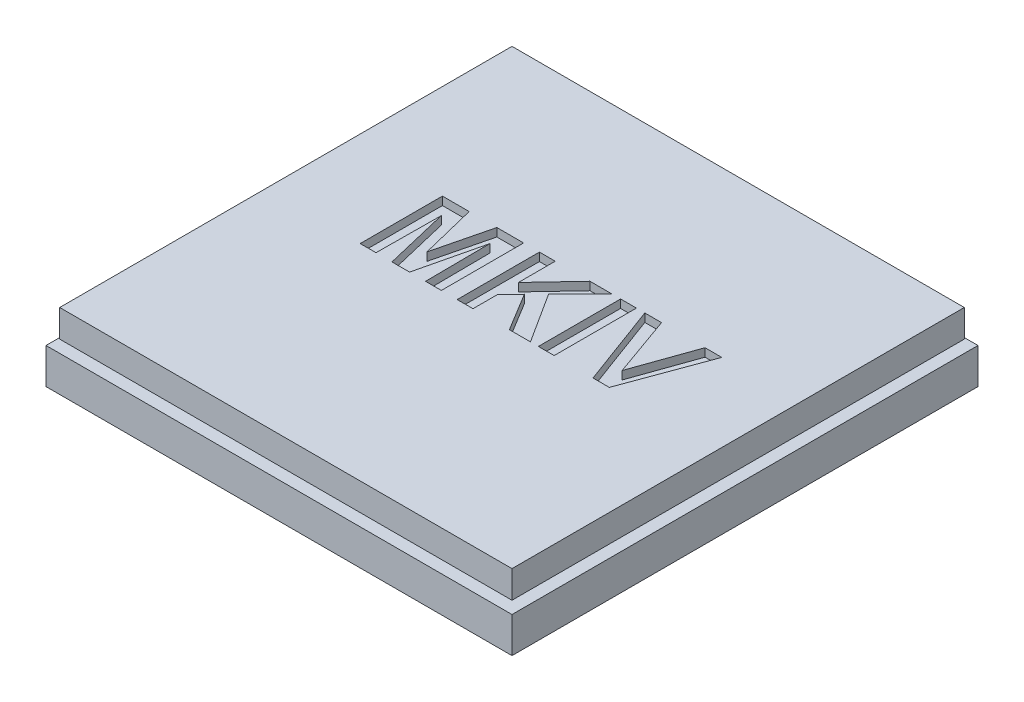
from build123d import *

# Parameters (mm, degrees)
SKETCH1_W           = 29.8
SKETCH1_H           = 29.8
BOSS_EXTRUDE1_DEPTH = 3
SKETCH2_W           = 33
SKETCH2_H           = 33
BOSS_EXTRUDE2_DEPTH = 2
SKETCH5_W           = 34
SKETCH5_H           = 34
SKETCH5_W_2         = 31
SKETCH5_H_2         = 31
BOSS_EXTRUDE4_DEPTH = 2.6
CHAMFER1_SIZE       = 0.5
CHAMFER1_SIZE2      = 0.866025404
SKETCH3_W           = 1.153846154
SKETCH3_H           = 6
CUT_EXTRUDE1_DEPTH  = 0.6


with BuildPart() as part:
    # Sketch1 → Boss-Extrude1 (new body)
    with BuildSketch(Plane(origin=(0, 0, 0), x_dir=(1, 0, 0), z_dir=(0, 1, 0))):
        Rectangle(SKETCH1_W, SKETCH1_H)
    extrude(amount=BOSS_EXTRUDE1_DEPTH)

    # Sketch2 → Boss-Extrude2 (add)
    with BuildSketch(Plane(origin=(0, 3, 0), x_dir=(1, 0, 0), z_dir=(0, 1, 0))):
        Rectangle(SKETCH2_W, SKETCH2_H)
    extrude(amount=BOSS_EXTRUDE2_DEPTH)

    # Chamfer1
    chamfer1_edges = [part.edges().sort_by_distance(p)[0] for p in [
        (0, 0, -14.9),
        (14.9, 0, 0),
        (0, 0, 14.9),
        (-14.9, 0, 0),
    ]]
    chamfer1_side = [part.faces().sort_by_distance(p)[0] for p in [
        (0, 0, 0),
    ]]
    chamfer(chamfer1_edges, length=CHAMFER1_SIZE, length2=CHAMFER1_SIZE2, reference=chamfer1_side[0])

    # Sketch3 → Cut-Extrude1 (cut)
    with BuildSketch(Plane(origin=(0, 5, 0), x_dir=(1, 0, 0), z_dir=(0, 1, 0))):
        Polygon((-9.576923077, -1.5), (-9.576923077, 4.5), (-7.625, 4.5), (-6.615384615, 0.407451923), (-5.605769231, 4.5), (-3.653846154, 4.5), (-3.653846154, -1.5), (-4.807692308, -1.5), (-4.846153846, 3.223557692), (-5.972355769, -1.5), (-7.258413462, -1.5), (-8.384615385, 3.223557692), (-8.423076923, -1.5), align=None)
        Polygon((-2.5, -1.5), (-2.5, 4.5), (-1.346153846, 4.5), (-1.346153846, 1.813701923), (1.183894231, 4.5), (2.769230769, 4.5), (0.490384615, 2.180288462), (2.846153846, -1.5), (1.308894231, -1.5), (-0.384615385, 1.287259615), (-1.346153846, 0.308894231), (-1.346153846, -1.5), align=None)
        with Locations((4, 1.5)):
            Rectangle(SKETCH3_W, SKETCH3_H)
        Polygon((7.411057692, -1.5), (5.192307692, 4.5), (6.411057692, 4.5), (8, 0.038461538), (9.582932692, 4.5), (10.807692308, 4.5), (8.597355769, -1.5), align=None)
    extrude(amount=-CUT_EXTRUDE1_DEPTH, mode=Mode.SUBTRACT)


with BuildPart() as body_2:
    # Sketch5 → Boss-Extrude4 (new body)
    with BuildSketch(Plane.XZ):
        Rectangle(SKETCH5_W, SKETCH5_H)
        Rectangle(SKETCH5_W_2, SKETCH5_H_2, mode=Mode.SUBTRACT)
    extrude(amount=-BOSS_EXTRUDE4_DEPTH)


solid = Compound([part.part, body_2.part])
